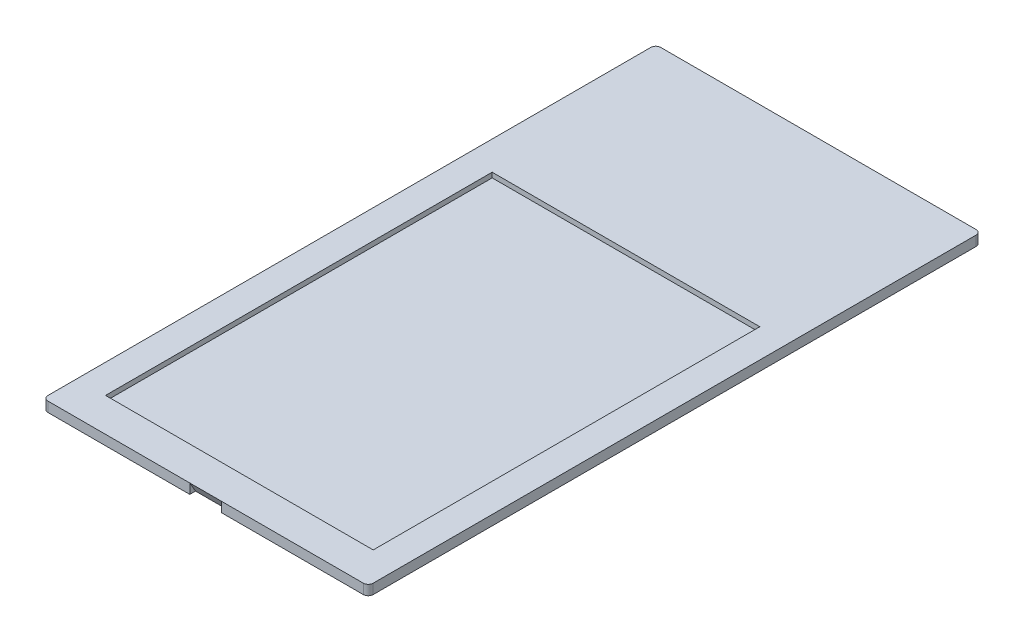
from build123d import *

# Parameters (mm, degrees)
SKETCH_1_W          = 65.6
SKETCH_1_H          = 123.6
EXTRUDE_1_DEPTH     = 2
CUT_EXTRUDE_3_DEPTH = 3.2
SKETCH_3_W          = 54
SKETCH_3_H          = 78
CUT_EXTRUDE_2_DEPTH = 1
FILLET_1_R          = 1


with BuildPart() as part:
    # 草图1 → 凸台-拉伸1 (new body)
    with BuildSketch(Plane(origin=(0, 0, 0), x_dir=(1, 0, 0), z_dir=(0, 1, 0))):
        with Locations((0, -64)):
            Rectangle(SKETCH_1_W, SKETCH_1_H)
    extrude(amount=-EXTRUDE_1_DEPTH)

    # 草图4 → 切除-拉伸3 (cut, symmetric)
    with BuildSketch(Plane(origin=(0, 0, 0), x_dir=(0, 0, -1), z_dir=(1, 0, 0))):
        Polygon((-125.8, 0), (-124.645299462, -2), (-125.8, -2), align=None)
        Polygon((-2.2, 0), (-2.2, -2), (-3.354700538, -2), align=None)
    extrude(amount=CUT_EXTRUDE_3_DEPTH, both=True, mode=Mode.SUBTRACT)

    # 草图3 → 切除-拉伸2 (cut)
    with BuildSketch(Plane(origin=(0, 0, 0), x_dir=(1, 0, 0), z_dir=(0, 1, 0))):
        with Locations((0, -80)):
            Rectangle(SKETCH_3_W, SKETCH_3_H)
    extrude(amount=-CUT_EXTRUDE_2_DEPTH, mode=Mode.SUBTRACT)

    # 圆角1
    fillet_1_edges = [part.edges().sort_by_distance(p)[0] for p in [
        (32.8, -1, 125.8),
        (32.8, -1, 2.2),
        (-32.8, -1, 2.2),
        (-32.8, -1, 125.8),
    ]]
    fillet(fillet_1_edges, radius=FILLET_1_R)


solid = part.part
